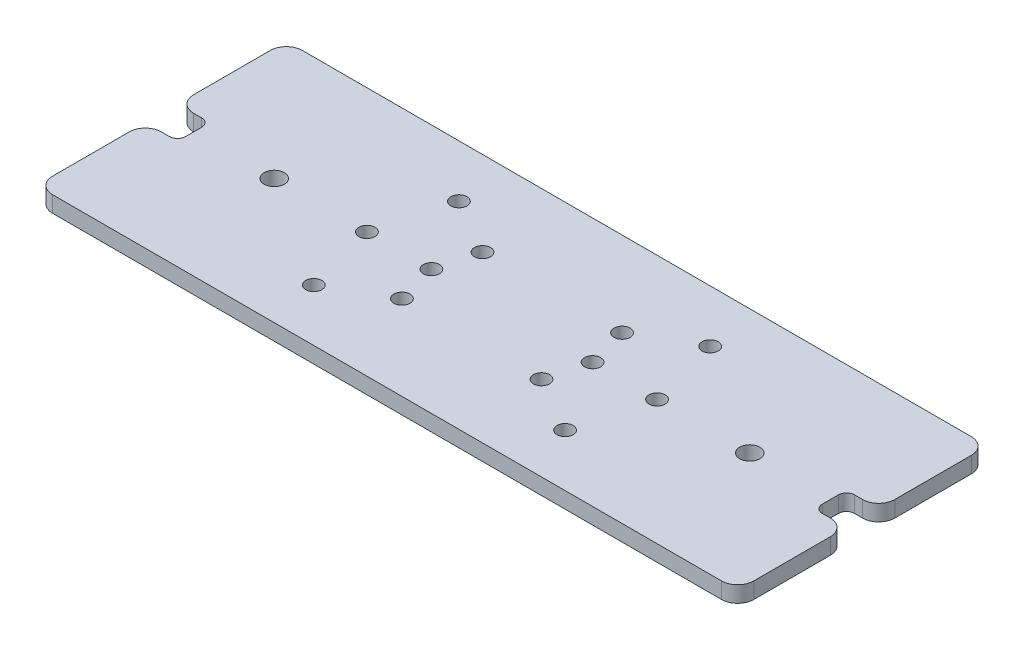
from build123d import *

# Parameters (mm, degrees)
SKETCH1_W                      = 276.225
SKETCH1_H                      = 98.425
BOSS_EXTRUDE1_DEPTH            = 6.35
F_5_16_0_332_DOWEL_HOLE1_D     = 7.9375
F_5_16_0_332_DOWEL_HOLE1_DEPTH = 6.35
SKETCH5_W                      = 12.7
SKETCH5_H                      = 12.7
CUT_EXTRUDE1_DEPTH             = 7.35
FILLET1_R                      = 3.175
FILLET2_R                      = 6.35
F_1_4_0_2500_DOWEL_HOLE1_D     = 6.35
F_1_4_0_2500_DOWEL_HOLE1_DEPTH = 6.35


with BuildPart() as part:
    # Sketch1 → Boss-Extrude1 (new body)
    with BuildSketch(Plane(origin=(0, 0, 0), x_dir=(1, 0, 0), z_dir=(0, 1, 0))):
        Rectangle(SKETCH1_W, SKETCH1_H)
    extrude(amount=BOSS_EXTRUDE1_DEPTH)

    # 5/16 (0.332) Dowel Hole1
    with Locations(Plane(origin=(0, 6.35, 0), x_dir=(1, 0, 0), z_dir=(0, 1, 0))):
        with Locations((-93.6625, 0), (93.6625, 0)):
            Hole(F_5_16_0_332_DOWEL_HOLE1_D / 2, depth=F_5_16_0_332_DOWEL_HOLE1_DEPTH)

    # Sketch5 → Cut-Extrude1 (cut, through all)
    with BuildSketch(Plane(origin=(0, 6.35, 0), x_dir=(1, 0, 0), z_dir=(0, 1, 0))):
        with Locations((-131.7625, 0)):
            Rectangle(SKETCH5_W, SKETCH5_H)
        with Locations((131.7625, 0)):
            Rectangle(SKETCH5_W, SKETCH5_H)
    extrude(amount=-CUT_EXTRUDE1_DEPTH, mode=Mode.SUBTRACT)

    # Fillet1
    fillet1_edges = [part.edges().sort_by_distance(p)[0] for p in [
        (-125.4125, 3.175, -6.35),
        (-125.4125, 3.175, 6.35),
        (125.4125, 3.175, 6.35),
        (125.4125, 3.175, -6.35),
    ]]
    fillet(fillet1_edges, radius=FILLET1_R)

    # Fillet2
    fillet2_edges = [part.edges().sort_by_distance(p)[0] for p in [
        (-138.1125, 3.175, 6.35),
        (-138.1125, 3.175, -6.35),
        (138.1125, 3.175, -6.35),
        (138.1125, 3.175, 6.35),
        (-138.1125, 3.175, -49.2125),
        (138.1125, 3.175, -49.2125),
        (138.1125, 3.175, 49.2125),
        (-138.1125, 3.175, 49.2125),
    ]]
    fillet(fillet2_edges, radius=FILLET2_R)

    # 1/4 (0.2500) Dowel Hole1
    with Locations(Plane(origin=(0, 6.35, 0), x_dir=(1, 0, 0), z_dir=(0, 1, 0))):
        with Locations((-57.15, 0), (-31.75, 0), (31.75, 0), (57.15, 0), (-49.493351826, 28.575), (-27.49630657, 15.875), (-27.49630657, -15.875), (-49.493351826, -28.575), (27.49630657, 15.875), (49.493351826, 28.575), (49.493351826, -28.575), (27.49630657, -15.875)):
            Hole(F_1_4_0_2500_DOWEL_HOLE1_D / 2, depth=F_1_4_0_2500_DOWEL_HOLE1_DEPTH)


solid = part.part
